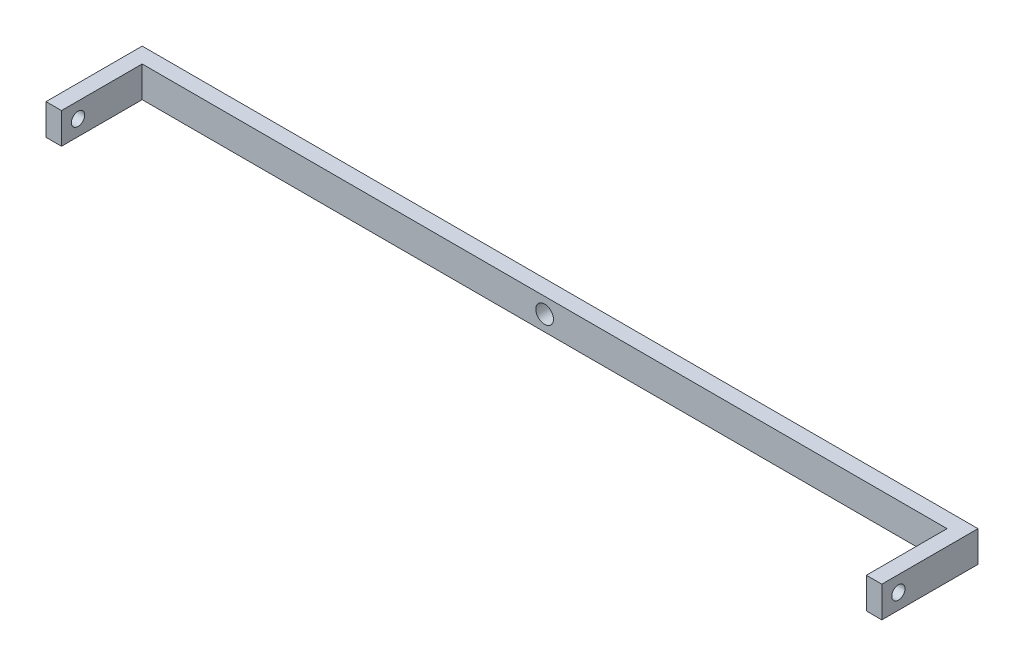
from build123d import *

# Parameters (mm, degrees)
BOSS_EXTRUDE1_DEPTH     = 3.5
SKETCH3_R               = 2
CUT_EXTRUDE1_DEPTH      = 7
SKETCH4_R               = 1.5
CUT_EXTRUDE2_DEPTH      = 1
CUT_EXTRUDE2_DEPTH_BACK = 190


with BuildPart() as part:
    # Sketch1 → Boss-Extrude1 (new body, symmetric)
    with BuildSketch(Plane(origin=(0, 0, 0), x_dir=(1, 0, 0), z_dir=(0, 1, 0))):
        Polygon((94.5, 1.75), (94.5, -20), (91, -20), (91, -1.75), (-91, -1.75), (-91, -20), (-94.5, -20), (-94.5, 1.75), align=None)
    extrude(amount=BOSS_EXTRUDE1_DEPTH, both=True)

    # Sketch3 → Cut-Extrude1 (cut)
    with BuildSketch(Plane(origin=(0, 0, -1.75), x_dir=(-1, 0, 0), z_dir=(0, 0, -1))):
        Circle(SKETCH3_R)
    extrude(amount=-CUT_EXTRUDE1_DEPTH, mode=Mode.SUBTRACT)

    # Sketch4 → Cut-Extrude2 (cut, two sides)
    with BuildSketch(Plane.ZY.offset(94.5)) as cut_extrude2_sk:
        with Locations((16.25, 0)):
            Circle(SKETCH4_R)
    extrude(amount=CUT_EXTRUDE2_DEPTH, mode=Mode.SUBTRACT)
    extrude(cut_extrude2_sk.sketch, amount=-CUT_EXTRUDE2_DEPTH_BACK, mode=Mode.SUBTRACT)


solid = part.part
